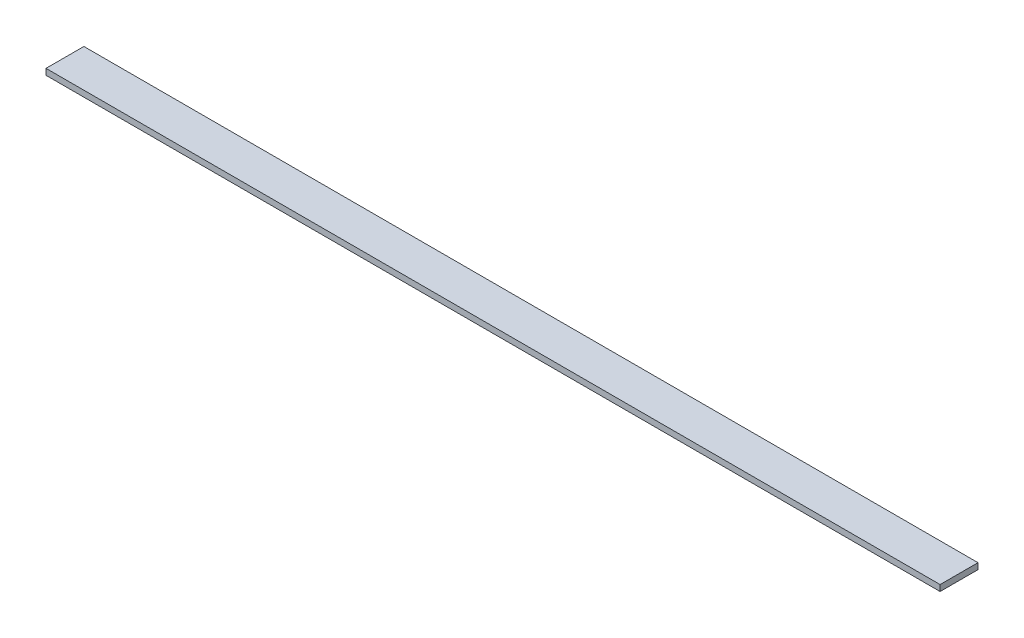
from build123d import *

# Parameters (mm, degrees)
SKETCH_1_W      = 1180
SKETCH_1_H      = 50
EXTRUDE_1_DEPTH = 8


with BuildPart() as part:
    # Эскиз1 → Бобышка-Вытянуть1 (new body)
    with BuildSketch(Plane(origin=(0, 0, 0), x_dir=(1, 0, 0), z_dir=(0, 1, 0))):
        Rectangle(SKETCH_1_W, SKETCH_1_H)
    extrude(amount=EXTRUDE_1_DEPTH)


solid = part.part
